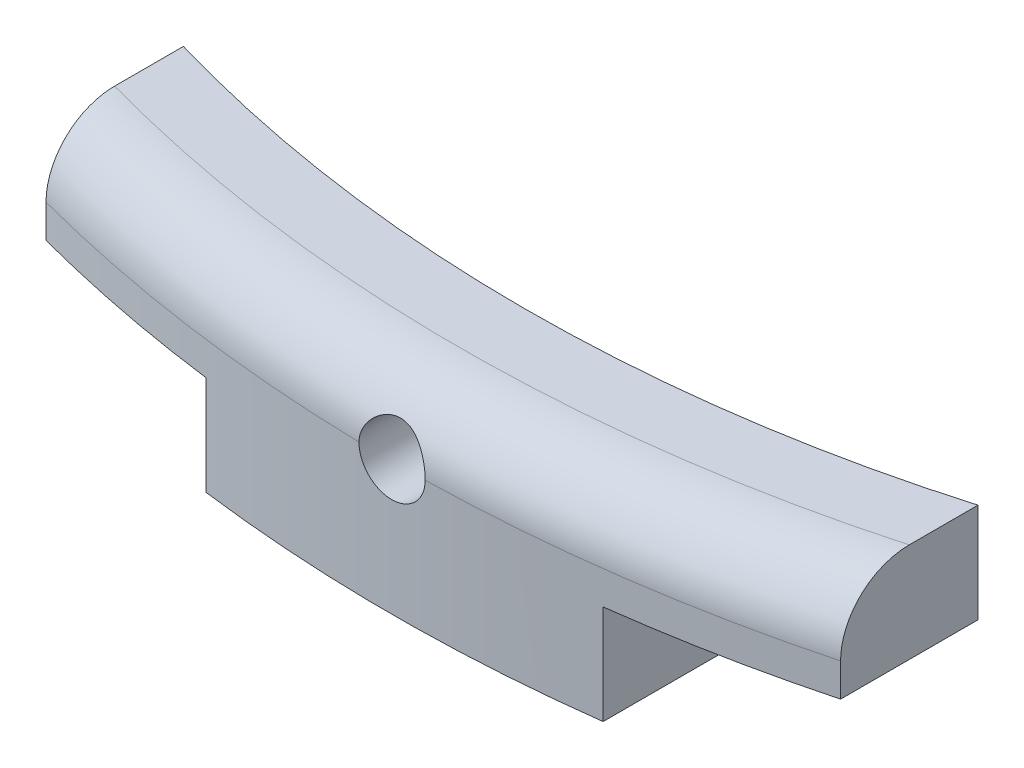
from build123d import *

# Parameters (mm, degrees)
BOSS_EXTRUDE1_DEPTH = 3
BOSS_EXTRUDE2_DEPTH = 1.5
FILLET1_R           = 1
CUT_EXTRUDE1_REACH  = 25.5
SKETCH3_R           = 0.5


with BuildPart() as part:
    # Sketch1 → Boss-Extrude1 (new body)
    with BuildSketch(Plane(origin=(0, 0, 0), x_dir=(1, 0, 0), z_dir=(0, 1, 0))):
        with BuildLine():
            Line((3, -23.307724042), (3, -21.289668856))
            ThreePointArc((3, -21.289668856), (0, -21.5), (-3, -21.289668856))
            Line((-3, -21.289668856), (-3, -23.307724042))
            ThreePointArc((-3, -23.307724042), (0, -23.5), (3, -23.307724042))
        make_face()
    extrude(amount=BOSS_EXTRUDE1_DEPTH)

    # Sketch2 → Boss-Extrude2 (add)
    with BuildSketch(Plane(origin=(0, 3, 0), x_dir=(1, 0, 0), z_dir=(0, 1, 0))):
        with BuildLine():
            Line((-6, -22.721135535), (-6, -20.645822822))
            ThreePointArc((-6, -20.645822822), (0, -21.5), (6, -20.645822822))
            Line((6, -20.645822822), (6, -22.721135535))
            ThreePointArc((6, -22.721135535), (0, -23.5), (-6, -22.721135535))
        make_face()
    extrude(amount=-BOSS_EXTRUDE2_DEPTH)

    # Fillet1
    fillet1_edges = [part.edges().sort_by_distance(p)[0] for p in [
        (0, 3, 23.5),
    ]]
    fillet(fillet1_edges, radius=FILLET1_R)

    # Sketch3 → Cut-Extrude1 (cut, up to next)
    with BuildSketch(Plane.XY, mode=Mode.PRIVATE) as cut_extrude1_sk1:
        with Locations((0, 2)):
            Circle(SKETCH3_R)
    cut_extrude1_tool1 = extrude(cut_extrude1_sk1.sketch, amount=CUT_EXTRUDE1_REACH, mode=Mode.PRIVATE) & part.part
    add(cut_extrude1_tool1.solids().sort_by_distance((0, 2, 0))[0], mode=Mode.SUBTRACT)


solid = part.part
